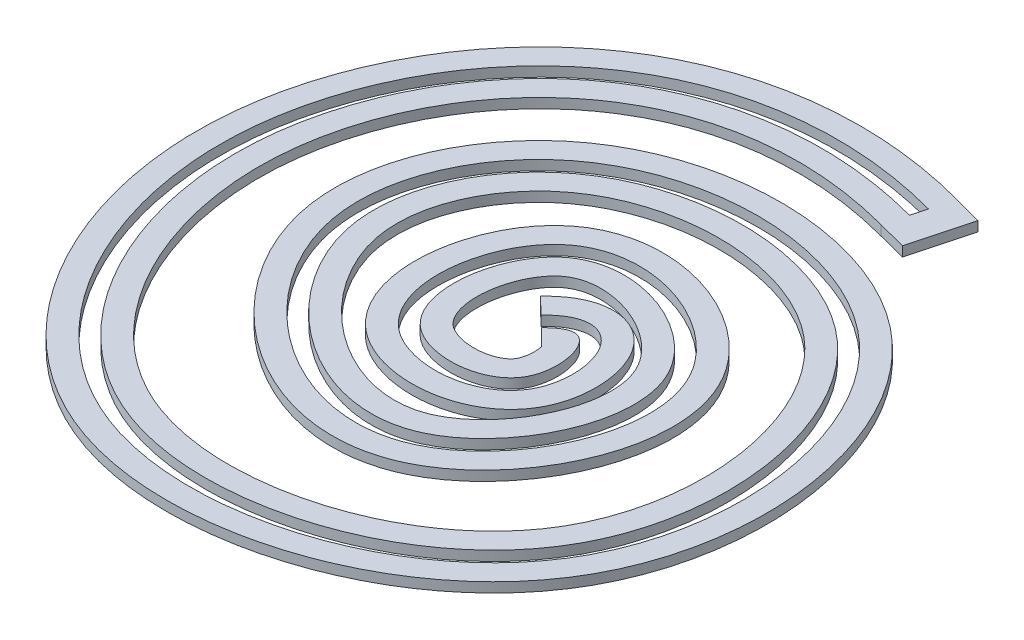
from build123d import *

# Parameters (mm, degrees)
BOSS_EXTRUDE1_DEPTH = 3.175


with BuildPart() as part:
    # Sketch1 → Boss-Extrude1 (new body)
    with BuildSketch(Plane(origin=(0, 0, 0), x_dir=(1, 0, 0), z_dir=(0, 1, 0))):
        with BuildLine():
            Line((52.057562898, 154.889864405), (61.370668714, 152.39690064))
            Line((61.370668714, 152.39690064), (56.21698403, 133.143989111))
            Line((56.21698403, 133.143989111), (46.885973353, 135.570064675))
            add(Edge.make_bspline(
                [(46.885973353, 135.570064675), (46.016928687, 135.8026935), (44.264166631, 136.254140996), (40.824105531, 137.069819627), (36.589892498, 137.943469933), (31.632697331, 138.760898922), (25.182322913, 139.554360909), (17.421227203, 140.007886838), (8.588338172, 139.748450723), (0.231113846, 138.740217592), (-10.287184437, 136.465693908), (-22.284866323, 131.998518113), (-34.893300846, 124.370017681), (-45.713235728, 114.763473775), (-54.687895509, 103.470688988), (-64.071136628, 86.593667687), (-69.373728213, 67.667205255), (-70.226606311, 48.234190937), (-68.109303754, 28.779088756), (-61.793929726, 10.108445345), (-51.905397016, -6.128141849), (-42.903001943, -16.70520625), (-32.503706757, -25.338061245), (-22.842061031, -30.663066135), (-14.509321738, -33.692313963), (-5.711668212, -35.944400006), (5.939134018, -37.275038029), (20.417993896, -36.517670075), (34.788585361, -33.475147693), (48.452149317, -28.26896938), (60.828448943, -21.063455168), (69.621747663, -13.563204918), (75.521155403, -6.762067933), (79.327122455, -1.290675307), (82.495091594, 4.58650228), (85.931269492, 13.019557996), (88.688822734, 24.437688303), (89.490323634, 38.88903542), (87.792743618, 53.355731889), (83.676277942, 67.107332331), (77.292325638, 79.434483646), (70.235846375, 88.013454958), (63.664629036, 93.593658559), (56.341027025, 98.388466546), (45.912253572, 102.901996089), (32.140517566, 105.727940116), (17.980208077, 105.843943038), (4.32874757, 103.226518964), (-7.972112324, 97.957262787), (-18.169012854, 90.183783592), (-26.105963035, 79.870558742), (-30.995308016, 68.072351702), (-32.093221011, 57.779237287), (-31.015210678, 49.673568168), (-28.491684682, 41.449616468), (-22.657817319, 31.018242601), (-12.36353172, 19.969865563), (-2.176456662, 13.139777332), (6.13834598, 9.65555673), (12.245367676, 8.114308413), (18.034005072, 7.68241987), (23.404832483, 8.350237528), (28.360930454, 10.119493915), (33.437828781, 13.273628783), (38.257161736, 17.659381568), (43.967993695, 24.829520862), (48.056797515, 33.379168167), (49.813507507, 41.923405016), (49.90939689, 47.973510013), (48.786075791, 53.420496982), (46.50951661, 58.139778706), (42.602041723, 62.829415989), (37.376279078, 66.962710967), (31.307048018, 70.161482691), (24.961014947, 72.13430076), (18.948781791, 72.720241742), (14.721918198, 72.088042019), (11.943317348, 71.025131686), (10.142069623, 69.97736671), (8.498514348, 68.597355153), (6.822856085, 66.669247427), (5.277817014, 64.283667043), (3.485090189, 60.59209645), (1.934281533, 55.292017072), (1.493811536, 48.794894), (2.507287971, 43.170517414), (4.228998108, 39.947976778), (5.67716865, 38.439114758), (6.622816564, 37.716830429), (7.793210982, 36.996509147), (9.612429649, 36.195038099), (13.094737203, 35.30165341), (17.005803639, 35.198660267), (20.44916166, 35.901599396), (22.592683029, 36.739645538), (24.153222246, 37.742643882), (25.140283685, 38.783695722), (25.72802416, 39.770963352), (26.306799938, 41.734687256), (26.454310577, 43.80001317), (26.344943491, 45.467173982), (26.227692427, 46.22572159), (26.150011131, 46.609582714)],
                knots=[0, 0, 0, 0, 0.001906675, 0.003813349, 0.007626698, 0.011440047, 0.015253397, 0.022880095, 0.030506793, 0.038133491, 0.04576019, 0.061013586, 0.076266983, 0.091520379, 0.106773776, 0.122027172, 0.152533965, 0.167787362, 0.183040759, 0.213547552, 0.228800948, 0.244054345, 0.259307741, 0.274561138, 0.282187836, 0.289814534, 0.305067931, 0.320321327, 0.335574724, 0.350828121, 0.366081517, 0.381334914, 0.388961612, 0.39658831, 0.404215008, 0.411841707, 0.427095103, 0.4423485, 0.457601896, 0.472855293, 0.488108689, 0.503362086, 0.510988784, 0.518615483, 0.533868879, 0.549122276, 0.564375672, 0.579629069, 0.594882465, 0.610135862, 0.625389258, 0.640642655, 0.655896051, 0.66352275, 0.671149448, 0.686402845, 0.701656241, 0.716909638, 0.724536336, 0.732163034, 0.739789732, 0.747416431, 0.755043129, 0.762669827, 0.770296526, 0.777923224, 0.79317662, 0.800803319, 0.808430017, 0.816056715, 0.823683413, 0.831310112, 0.83893681, 0.846563508, 0.854190206, 0.861816905, 0.869443603, 0.873256952, 0.877070301, 0.88088365, 0.884697, 0.888510349, 0.892323698, 0.899950396, 0.907577094, 0.915203793, 0.922830491, 0.92664384, 0.928550515, 0.930457189, 0.934270538, 0.938083887, 0.945710586, 0.949523935, 0.953337284, 0.957150633, 0.960963982, 0.964777331, 0.968590681, 0.97240403, 0.974310704, 0.976217379, 0.976217379, 0.976217379, 0.976217379], degree=3))
            Line((26.150011131, 46.609582714), (20.842364508, 51.909018082))
            add(Edge.make_bspline(
                [(48.825319433, 142.814989574), (47.888189764, 143.065843623), (45.998809642, 143.552017529), (42.283672463, 144.430182133), (37.702355579, 145.368670994), (32.323969684, 146.242055336), (25.306775232, 147.080172873), (16.829479187, 147.531858749), (7.133854268, 147.174037397), (-2.077972051, 145.969059033), (-13.707584586, 143.301812596), (-27.006639181, 138.106150402), (-40.935141674, 129.284844617), (-52.768803896, 118.25889496), (-62.428351284, 105.41208248), (-72.289546224, 86.377213643), (-77.452505998, 65.282847495), (-77.541089297, 43.750146203), (-74.324301686, 22.426579139), (-64.522953627, -2.747733898), (-48.075061285, -23.092815858), (-31.614315033, -34.842615808), (-17.760042996, -40.965125548), (-2.560459739, -44.217095594), (18.661949797, -44.914582089), (40.134691186, -40.328653005), (59.440526481, -30.964661304), (72.240312432, -21.693751595), (82.80138568, -10.337387031), (90.512783602, 3.01960776), (95.24369744, 18.088347318), (97.066532483, 34.084947059), (96.01811861, 50.29435977), (92.169745483, 65.974430922), (85.603780109, 80.388416408), (76.434166249, 92.837501071), (64.722023498, 102.577892097), (50.671098709, 109.304776513), (35.217446016, 112.98528223), (19.226820921, 113.534396081), (3.602724076, 110.910084598), (-10.774252891, 105.110443405), (-23.031749181, 96.092679073), (-32.491774091, 84.036001582), (-38.376071892, 70.028896247), (-39.696799855, 57.532877796), (-38.263759801, 47.520304009), (-35.050904538, 37.55690251), (-28.040215956, 25.534741519), (-16.0662716, 13.16713549), (-1.867327742, 4.14450639), (10.646121133, 0.421424476), (20.380830865, 0.235603405), (27.39696023, 1.587449196), (34.072566051, 4.607239244), (42.432466174, 10.700868179), (51.214653063, 21.46924206), (56.365925412, 34.461622877), (57.578200026, 44.923972027), (56.882717089, 52.506908284), (54.469377072, 59.534685783), (50.106455425, 65.907732051), (44.109331272, 71.463044462), (36.974046417, 75.87173181), (29.197703738, 78.878162986), (21.301238794, 80.246499859), (13.811405886, 79.789695498), (8.298968853, 77.786953419), (4.499098407, 75.146539017), (1.058078783, 71.724570158), (-2.484959567, 66.17315453), (-5.190631436, 58.243326076), (-6.115327776, 49.891563601), (-5.097118489, 41.97885535), (-2.083327639, 35.334566252), (2.90802821, 30.629042418), (10.242586495, 27.923134633), (18.438885121, 27.547553924), (24.742014367, 29.251603093), (28.763344776, 31.737990786), (31.149771579, 34.127551548), (32.812819067, 37.047506482), (33.78498435, 40.684208744), (34.019189349, 44.630623981), (33.539043788, 48.500002824), (32.422060864, 51.88684586), (30.815015726, 54.391325371), (29.05667506, 55.681738881), (27.581008549, 55.951095697), (25.97243227, 55.622327408), (24.748280265, 55.069604538), (23.646710238, 54.370581966), (22.76482382, 53.708472695), (21.985061793, 53.032519646), (21.341876361, 52.4191795), (21.005269072, 52.07852852), (20.842364508, 51.909018082)],
                knots=[0, 0, 0, 0, 0.001953125, 0.00390625, 0.0078125, 0.01171875, 0.015625, 0.0234375, 0.03125, 0.0390625, 0.046875, 0.0625, 0.078125, 0.09375, 0.109375, 0.125, 0.15625, 0.171875, 0.1875, 0.21875, 0.25, 0.265625, 0.28125, 0.296875, 0.3125, 0.34375, 0.359375, 0.375, 0.390625, 0.40625, 0.421875, 0.4375, 0.453125, 0.46875, 0.484375, 0.5, 0.515625, 0.53125, 0.546875, 0.5625, 0.578125, 0.59375, 0.609375, 0.625, 0.640625, 0.65625, 0.6640625, 0.671875, 0.6875, 0.703125, 0.71875, 0.734375, 0.7421875, 0.75, 0.7578125, 0.765625, 0.78125, 0.796875, 0.8046875, 0.8125, 0.8203125, 0.828125, 0.8359375, 0.84375, 0.8515625, 0.859375, 0.8671875, 0.875, 0.87890625, 0.8828125, 0.890625, 0.8984375, 0.90625, 0.9140625, 0.921875, 0.9296875, 0.9375, 0.9453125, 0.953125, 0.95703125, 0.9609375, 0.96484375, 0.96875, 0.97265625, 0.9765625, 0.98046875, 0.984375, 0.98828125, 0.9921875, 0.994140625, 0.99609375, 0.997070312, 0.998046875, 0.999023438, 0.999511719, 1, 1, 1, 1], degree=3))
            Line((48.825319433, 142.814989574), (50.118216819, 147.644939506))
            add(Edge.make_bspline(
                [(50.118216819, 147.644939506), (49.149693987, 147.904196984), (47.197708512, 148.406483174), (43.353982357, 149.315073696), (38.607583026, 150.287469487), (33.023899671, 151.194317128), (25.724236547, 152.066331876), (16.878809696, 152.538406682), (6.723607696, 152.164474844), (-2.957579451, 150.898802358), (-15.213889287, 148.088694119), (-29.273493403, 142.597972599), (-44.010376039, 133.264108145), (-56.509737215, 121.615341895), (-66.684636837, 108.07994044), (-77.044016357, 88.077518983), (-82.454236632, 65.968835857), (-82.547215783, 43.37522744), (-79.178852596, 21.066864911), (-70.98526697, 0.009449961), (-58.556419404, -18.121924609), (-47.254783311, -29.826222186), (-34.129331254, -39.206476691), (-19.280323393, -45.766111791), (-3.149984084, -49.208414564), (19.203628553, -49.936930624), (41.693759207, -45.132254365), (62.003753328, -35.286601809), (75.558653764, -25.479625317), (84.950480045, -15.374510314), (91.007105783, -6.174232702), (95.974469267, 3.708293073), (100.17014627, 17.062488368), (102.090764881, 33.971652377), (100.986100623, 51.053467428), (96.926008024, 67.604734427), (89.96176517, 82.917265017), (81.766682851, 94.037948388), (73.793811843, 101.574144645), (64.887464904, 108.050045118), (52.333205132, 114.062376897), (35.881343157, 117.973487483), (18.905950903, 118.556539157), (2.259375037, 115.769019794), (-10.620242473, 110.573026151), (-19.88055588, 104.65079031), (-28.280303771, 97.521109402), (-36.844431594, 86.617259726), (-43.279239852, 71.319707051), (-44.753207731, 57.528069378), (-43.15446239, 46.369046904), (-39.60763576, 35.395967501), (-32.04092871, 22.461524409), (-19.268674039, 9.270629671), (-4.042628606, -0.424384985), (9.723260609, -4.560687515), (20.782616841, -4.78680715), (28.924880225, -3.222715771), (36.654512474, 0.282314397), (46.002857755, 7.120196703), (55.587790091, 18.901649535), (61.241028751, 33.097746953), (62.61171181, 44.826531597), (61.831009036, 53.522844124), (58.982782371, 61.82613162), (53.884212126, 69.24819032), (47.137663937, 75.478325448), (36.572224207, 82.002722278), (24.567904522, 85.446952588), (12.857549408, 84.767808707), (6.064363609, 82.331183141), (1.256493839, 78.987179909), (-2.946215837, 74.792510295), (-7.053002823, 68.31274997), (-10.107876097, 59.339528986), (-11.15917674, 49.896367925), (-10.003994237, 40.693070504), (-6.935757763, 33.832307411), (-3.038238383, 29.296960275), (0.642190009, 26.545365504), (4.839692293, 24.562436519), (10.895634755, 22.86609755), (18.933465968, 22.500668293), (26.600755801, 24.52536842), (31.860224313, 27.756131838), (35.157514709, 31.028306379), (37.52886744, 35.220072125), (39.164704565, 41.489985051), (38.930793612, 48.095895156), (37.027817769, 53.943612568), (34.714851768, 57.677991531), (31.856077758, 59.944197242), (28.995550933, 60.823135695), (26.679167803, 60.901162331), (24.313298663, 60.379384341), (21.960340175, 59.294178145), (19.998983047, 57.9296696), (18.433333344, 56.572462679), (17.622411659, 55.774354428), (17.237282935, 55.373608513)],
                knots=[0, 0, 0, 0, 0.001953125, 0.00390625, 0.0078125, 0.01171875, 0.015625, 0.0234375, 0.03125, 0.0390625, 0.046875, 0.0625, 0.078125, 0.09375, 0.109375, 0.125, 0.15625, 0.171875, 0.1875, 0.21875, 0.234375, 0.25, 0.265625, 0.28125, 0.296875, 0.3125, 0.34375, 0.359375, 0.375, 0.390625, 0.3984375, 0.40625, 0.421875, 0.4375, 0.453125, 0.46875, 0.484375, 0.5, 0.5078125, 0.515625, 0.53125, 0.546875, 0.5625, 0.578125, 0.59375, 0.6015625, 0.609375, 0.625, 0.640625, 0.65625, 0.6640625, 0.671875, 0.6875, 0.703125, 0.71875, 0.734375, 0.7421875, 0.75, 0.7578125, 0.765625, 0.78125, 0.796875, 0.8046875, 0.8125, 0.8203125, 0.828125, 0.8359375, 0.84375, 0.859375, 0.8671875, 0.875, 0.87890625, 0.8828125, 0.890625, 0.8984375, 0.90625, 0.9140625, 0.921875, 0.92578125, 0.9296875, 0.93359375, 0.9375, 0.9453125, 0.953125, 0.95703125, 0.9609375, 0.96484375, 0.96875, 0.9765625, 0.98046875, 0.984375, 0.98828125, 0.990234375, 0.9921875, 0.994140625, 0.99609375, 0.998046875, 0.999023438, 1, 1, 1, 1], degree=3))
            Line((17.237282935, 55.373608513), (11.829660577, 60.57049416))
            add(Edge.make_bspline(
                [(52.057562898, 154.889864405), (51.041950323, 155.161727025), (48.996056816, 155.68818164), (44.959447197, 156.642411039), (39.965424198, 157.665667226), (34.073794652, 158.622709816), (26.350428519, 159.54557038), (16.952805459, 160.048228581), (6.108237837, 159.650131014), (-4.27699055, 158.293417345), (-17.473346338, 155.269016406), (-32.673774742, 149.33570586), (-48.623227563, 139.233003562), (-62.121137285, 126.650011829), (-73.069064829, 112.081729133), (-84.175723353, 90.62796769), (-89.956821374, 66.997876516), (-90.05642468, 42.812749919), (-86.460575159, 19.027831716), (-77.738982515, -3.410437683), (-64.408609719, -22.866874782), (-52.201054194, -35.52326058), (-40.272954904, -44.041888942), (-29.751126597, -49.368357744), (-18.628210502, -53.584084345), (-4.038227853, -56.69651631), (14.004834407, -57.278188359), (32.023043042, -54.896931483), (49.486570556, -49.697298651), (65.849199602, -41.769923178), (80.533590516, -31.155115254), (90.822039842, -20.101277302), (97.518882658, -9.929599663), (102.991848175, 0.963929143), (107.557883873, 15.527324845), (110.314537743, 39.891137242), (106.579394446, 64.498080476), (96.496637154, 86.707287648), (87.481135969, 98.961022606), (78.603261393, 107.356229054), (68.656516179, 114.586700947), (54.823572557, 121.195389267), (36.878009698, 125.456493666), (18.424154762, 126.090348768), (0.245495103, 123.054344299), (-13.986683308, 117.326242056), (-24.341334871, 110.708595824), (-33.791408551, 102.68732383), (-43.371672116, 90.484741353), (-49.425854212, 76.131944411), (-51.653113054, 63.808893498), (-51.876876029, 54.302672918), (-50.49016246, 44.642190926), (-47.45521147, 35.274855292), (-43.08066068, 26.439823849), (-35.714587763, 15.443545032), (-24.073278231, 3.428485852), (-10.096151318, -5.497785536), (2.07436925, -10.124732924), (11.601009477, -12.107463646), (21.390243859, -12.31922708), (29.562132183, -10.753854979), (35.899997689, -8.317889995), (41.865242814, -5.21268035), (48.655777524, -0.240503913), (55.674018956, 7.076172002), (61.49241632, 15.45361862), (65.98185471, 24.651639281), (68.957646886, 34.460083746), (70.163776505, 44.675830982), (69.397604156, 53.332527289), (67.515886036, 60.131616114), (65.416150976, 65.108702772), (62.635365467, 69.792399908), (58.248607945, 75.447988202), (51.676806065, 81.506252129), (42.574197054, 87.123981457), (32.626736845, 90.979757917), (22.149057326, 92.826426722), (13.214949985, 92.335262658), (6.196070504, 90.377801072), (1.133000654, 88.048964807), (-3.607352595, 84.7477134), (-7.617100351, 80.733278366), (-10.930667074, 76.244226683), (-14.503248842, 69.766532565), (-17.482899291, 60.983278116), (-18.726074327, 49.904755026), (-17.588224959, 40.617647508), (-15.027213374, 33.462125954), (-12.14709711, 28.373014916), (-8.872685313, 24.558176482), (-5.697798976, 21.896945818), (-2.294115848, 19.625250612), (2.23223081, 17.491368369), (9.827765384, 15.37543967), (17.710221591, 15.014501905), (25.494778165, 16.441645582), (31.169970526, 18.522034644), (36.506486492, 21.778697688), (40.387267962, 25.628812162), (42.894120989, 29.402407826), (44.866094028, 33.544462767), (46.216489038, 38.775483275), (46.579104255, 45.034958846), (45.830910057, 51.14596858), (43.940531124, 57.024571894), (41.112123712, 61.690213791), (37.620406717, 65.018557472), (34.262591234, 67.069329143), (30.235147787, 68.310699203), (25.92863058, 68.44459318), (21.825383903, 67.516909163), (18.143525252, 65.794054941), (15.390286743, 63.864031037), (13.326369792, 62.07134078), (12.316118799, 61.076678544), (11.829660577, 60.57049416)],
                knots=[0, 0, 0, 0, 0.001953125, 0.00390625, 0.0078125, 0.01171875, 0.015625, 0.0234375, 0.03125, 0.0390625, 0.046875, 0.0625, 0.078125, 0.09375, 0.109375, 0.125, 0.15625, 0.171875, 0.1875, 0.21875, 0.234375, 0.25, 0.265625, 0.2734375, 0.28125, 0.296875, 0.3125, 0.328125, 0.34375, 0.359375, 0.375, 0.390625, 0.3984375, 0.40625, 0.421875, 0.4375, 0.46875, 0.484375, 0.5, 0.5078125, 0.515625, 0.53125, 0.546875, 0.5625, 0.578125, 0.59375, 0.6015625, 0.609375, 0.625, 0.640625, 0.6484375, 0.65625, 0.6640625, 0.671875, 0.6796875, 0.6875, 0.703125, 0.71875, 0.7265625, 0.734375, 0.7421875, 0.75, 0.75390625, 0.7578125, 0.765625, 0.7734375, 0.78125, 0.7890625, 0.796875, 0.8046875, 0.8125, 0.81640625, 0.8203125, 0.82421875, 0.828125, 0.8359375, 0.84375, 0.8515625, 0.859375, 0.8671875, 0.87109375, 0.875, 0.87890625, 0.8828125, 0.88671875, 0.890625, 0.8984375, 0.90625, 0.9140625, 0.91796875, 0.921875, 0.92578125, 0.927734375, 0.9296875, 0.93359375, 0.9375, 0.9453125, 0.94921875, 0.953125, 0.95703125, 0.9609375, 0.962890625, 0.96484375, 0.96875, 0.97265625, 0.9765625, 0.98046875, 0.984375, 0.986328125, 0.98828125, 0.990234375, 0.9921875, 0.994140625, 0.99609375, 0.998046875, 0.999023438, 1, 1, 1, 1], degree=3))
        make_face()
    extrude(amount=BOSS_EXTRUDE1_DEPTH)


solid = part.part
